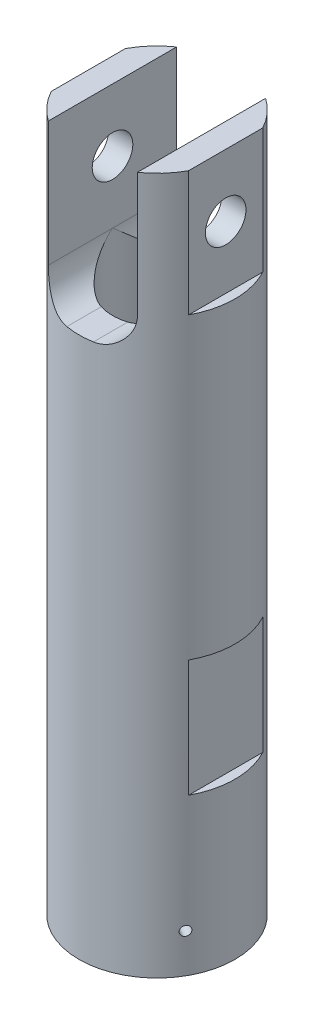
from build123d import *

# Parameters (mm, degrees)
SKETCH1_R                                     = 12.7
SKETCH1_R_2                                   = 4.826
SOCKET_HEAD_STOP_DEPTH                        = 5.08
SKETCH2_R                                     = 12.7
SKETCH2_R_2                                   = 7.239
MAIN_BODY_DEPTH                               = 100.70719
ROD_END_MOUNTING_HOLES_DEPTH                  = 103.29622729
ROD_END_MOUNTING_HOLES_DEPTH_BACK             = 103.29622729
SKETCH6_R                                     = 3.302
ROD_END_BODY_HOLES_AND_WRENCH_CUTS_DEPTH      = 103.296227413
ROD_END_BODY_HOLES_AND_WRENCH_CUTS_DEPTH_BACK = 103.296227413
SKETCH3_W                                     = 1.524
SKETCH3_H                                     = 20.32
SKETCH3_H_2                                   = 19.05
RACK_START                                    = 12.7
SKETCH4_R                                     = 12.7
SKETCH4_R_2                                   = 10.414
RACK_COVER_DEPTH                              = 12.7
SAFETY_WIRE_HOLES_DEPTH                       = 103.296227413
SAFETY_WIRE_HOLES_DEPTH_BACK                  = 103.296227413
SKETCH7_R                                     = 0.762


with BuildPart() as part:
    # Sketch1 → Socket Head Stop (new body)
    with BuildSketch(Plane(origin=(0, 0, 0), x_dir=(1, 0, 0), z_dir=(0, 1, 0))):
        Circle(SKETCH1_R)
        Circle(SKETCH1_R_2, mode=Mode.SUBTRACT)
    extrude(amount=SOCKET_HEAD_STOP_DEPTH)

    # Sketch2 → Main Body (add)
    with BuildSketch(Plane(origin=(0, 0, 0), x_dir=(1, 0, 0), z_dir=(0, 1, 0))):
        Circle(SKETCH2_R)
        Circle(SKETCH2_R_2, mode=Mode.SUBTRACT)
    extrude(amount=MAIN_BODY_DEPTH)

    # Sketch6 → Rod End Mounting Holes (cut, two sides: drawn at the far end of the back side and taken through both)
    with BuildSketch(Plane(origin=(0, 0, 0), x_dir=(0, 0, -1), z_dir=(1, 0, 0)).offset(-ROD_END_MOUNTING_HOLES_DEPTH_BACK)):
        with Locations((0, 90.54719)):
            Circle(SKETCH6_R)
    extrude(amount=ROD_END_MOUNTING_HOLES_DEPTH + ROD_END_MOUNTING_HOLES_DEPTH_BACK, mode=Mode.SUBTRACT)

    # Sketch3 → Rod End Body Holes And Wrench Cuts (cut, two sides: drawn at the far end of the back side and taken through both)
    with BuildSketch(Plane.XY.offset(-ROD_END_BODY_HOLES_AND_WRENCH_CUTS_DEPTH_BACK)):
        with BuildLine():
            Line((7.239, 100.70719), (-7.239, 100.70719))
            Line((-7.239, 100.70719), (-7.239, 80.38719))
            ThreePointArc((-7.239, 80.38719), (-5.751102448, 76.795087552), (-2.159, 75.30719))
            Line((-2.159, 75.30719), (2.159, 75.30719))
            ThreePointArc((2.159, 75.30719), (5.751102448, 76.795087552), (7.239, 80.38719))
            Line((7.239, 80.38719), (7.239, 100.70719))
        make_face()
        with Locations((11.938, 90.54719)):
            Rectangle(SKETCH3_W, SKETCH3_H)
        with Locations((-11.938, 90.54719)):
            Rectangle(SKETCH3_W, SKETCH3_H)
        with Locations((11.938, 22.225)):
            Rectangle(SKETCH3_W, SKETCH3_H_2)
        with Locations((-11.938, 22.225)):
            Rectangle(SKETCH3_W, SKETCH3_H_2)
    extrude(amount=ROD_END_BODY_HOLES_AND_WRENCH_CUTS_DEPTH + ROD_END_BODY_HOLES_AND_WRENCH_CUTS_DEPTH_BACK, mode=Mode.SUBTRACT)

    # Sketch4 → Rack Cover (add)
    with BuildSketch(Plane.XZ.offset(RACK_START)):
        Circle(SKETCH4_R)
        Circle(SKETCH4_R_2, mode=Mode.SUBTRACT)
    extrude(amount=-RACK_COVER_DEPTH)

    # Sketch7 → Safety Wire Holes (cut, two sides: drawn at the far end of the back side and taken through both)
    with BuildSketch(Plane(origin=(0, 0, 0), x_dir=(0, 1, 0), z_dir=(0.8660254037844398, 0, 0.499999999999998)).offset(-SAFETY_WIRE_HOLES_DEPTH_BACK)):
        with Locations((-6.35, 0)):
            Circle(SKETCH7_R)
    extrude(amount=SAFETY_WIRE_HOLES_DEPTH + SAFETY_WIRE_HOLES_DEPTH_BACK, mode=Mode.SUBTRACT)


solid = part.part
